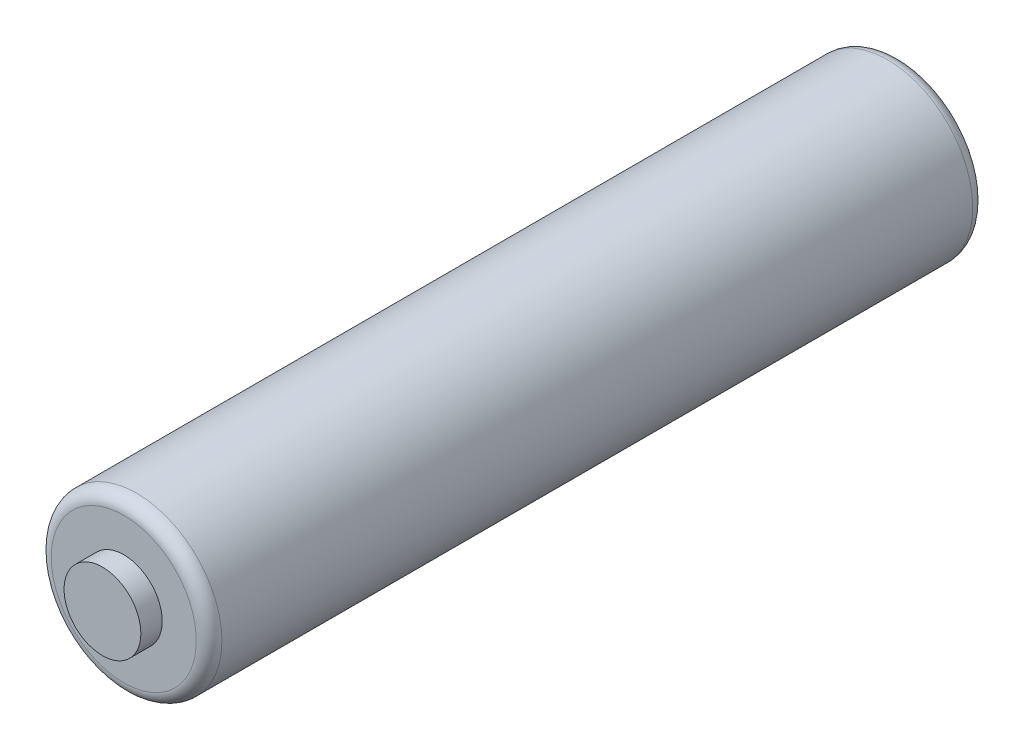
from build123d import *

# Parameters (mm, degrees)
FILLET1_R = 4.7625


with BuildPart() as part:
    # Sketch1 → Revolve1 (revolve)
    with BuildSketch(Plane(origin=(0, 0, 0), x_dir=(0, 0, -1), z_dir=(1, 0, 0))):
        Polygon((-152.4, -7.14375), (152.4, -7.14375), (152.4, 7.14375), (144.4625, 7.14375), (144.4625, 24.60625), (-144.4625, 24.60625), (-144.4625, 7.14375), (-152.4, 7.14375), align=None)
    revolve(axis=Axis((0, -7.14375, 152.4), (0, 0, -1)))

    # Fillet1
    fillet1_edges = [part.edges().sort_by_distance(p)[0] for p in [
        (0, -38.89375, -144.4625),
        (0, -38.89375, 144.4625),
    ]]
    fillet(fillet1_edges, radius=FILLET1_R)


solid = part.part
